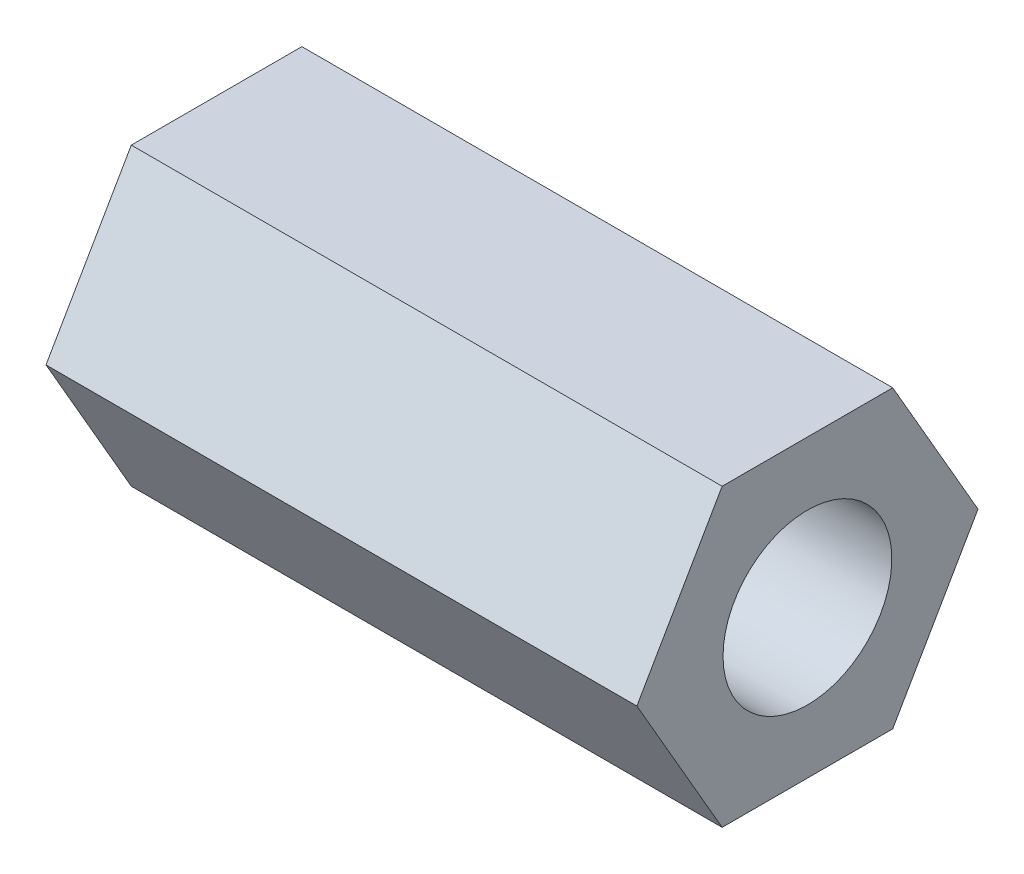
from build123d import *

# Parameters (mm, degrees)
BOSS_EXTRUDE1_DEPTH = 22.225
SKETCH2_R           = 3.175
CUT_EXTRUDE1_DEPTH  = 22.225


with BuildPart() as part:
    # Sketch1 → Boss-Extrude1 (new body)
    with BuildSketch(Plane(origin=(0, 0, 0), x_dir=(0, 0, -1), z_dir=(1, 0, 0))):
        Polygon((0, -5.55625), (0, 5.55625), (-3.207902433, 5.55625), (-6.415804866, 0), (-3.207902433, -5.55625), align=None)
        Polygon((3.207902433, 5.55625), (0, 5.55625), (0, -5.55625), (3.207902433, -5.55625), (6.415804866, 0), align=None)
    extrude(amount=BOSS_EXTRUDE1_DEPTH)

    # Sketch2 → Cut-Extrude1 (cut)
    with BuildSketch(Plane.ZY):
        Circle(SKETCH2_R)
    extrude(amount=-CUT_EXTRUDE1_DEPTH, mode=Mode.SUBTRACT)


solid = part.part
